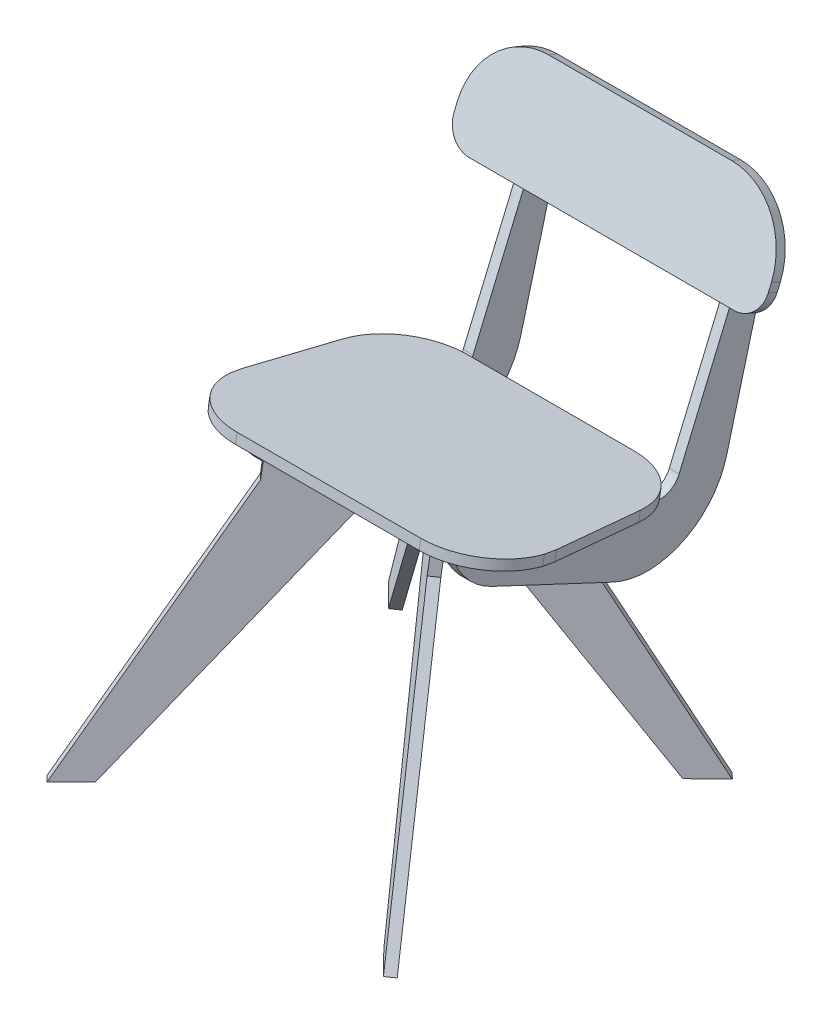
from build123d import *

# Parameters (mm, degrees)
BOSS_EXTRUDE1_DEPTH        = 192.05
BOSS_EXTRUDE1_DEPTH_BACK   = 192.05
BOSS_EXTRUDE1_2_DEPTH      = 192.05
BOSS_EXTRUDE1_2_DEPTH_BACK = 192.05
SKETCH3_OUTSIDE_W          = 508.562
SKETCH3_OUTSIDE_H          = 558.651
CUT_EXTRUDE1_DEPTH         = 12
SKETCH4_OUTSIDE_W          = 508.562
SKETCH4_OUTSIDE_H          = 526.289
CUT_EXTRUDE2_DEPTH         = 12
BOSS_EXTRUDE4_START        = 120
BOSS_EXTRUDE4_DEPTH        = 12
BOSS_EXTRUDE10_DEPTH       = 6


with BuildPart() as part:
    # Sketch2 → Boss-Extrude1 (new, two sides: drawn at the far end of the back side and taken through both)
    with BuildSketch(Plane(origin=(0, 0, 0), x_dir=(0, 0, -1), z_dir=(1, 0, 0)).offset(-BOSS_EXTRUDE1_DEPTH_BACK)):
        Polygon((0, 0), (-270.822132078, 47.753248858), (-272.90591021, 35.935555822), (-2.083778132, -11.817693036), align=None)
    extrude(amount=BOSS_EXTRUDE1_DEPTH + BOSS_EXTRUDE1_DEPTH_BACK)

    # Sketch3 outside → Cut-Extrude1 (cut)
    with BuildSketch(Plane(origin=(0, 0, 0), x_dir=(1, 0, 0), z_dir=(0, 0.9848077530122092, -0.17364817766692398))):
        with Locations((0, -96.4215)):
            Rectangle(SKETCH3_OUTSIDE_W, SKETCH3_OUTSIDE_H)
        with BuildLine():
            Line((0, -275), (112.39737442, -275))
            ThreePointArc((112.39737442, -275), (171.471178999, -248.947063059), (192.068830938, -187.757140317))
            Line((192.068830938, -187.757140317), (181.614285483, -72.757140317))
            ThreePointArc((181.614285483, -72.757140317), (155.889892025, -20.926195422), (101.942828966, 0))
            Line((101.942828966, 0), (-101.942828966, 0))
            ThreePointArc((-101.942828966, 0), (-155.889892025, -20.926195422), (-181.614285483, -72.757140317))
            Line((-181.614285483, -72.757140317), (-192.068830938, -187.757140317))
            ThreePointArc((-192.068830938, -187.757140317), (-171.471178999, -248.947063059), (-112.39737442, -275))
            Line((-112.39737442, -275), (0, -275))
        make_face(mode=Mode.SUBTRACT)
    extrude(amount=-CUT_EXTRUDE1_DEPTH, mode=Mode.SUBTRACT)



with BuildPart() as body_2:
    # Sketch2 → Boss-Extrude1 2 (new, two sides: drawn at the far end of the back side and taken through both)
    with BuildSketch(Plane(origin=(0, 0, 0), x_dir=(0, 0, -1), z_dir=(1, 0, 0)).offset(-BOSS_EXTRUDE1_2_DEPTH_BACK)):
        Polygon((109.404715977, 257.741358967), (62.516980558, 147.280776552), (73.5630388, 142.592003011), (120.450774218, 253.052585425), align=None)
    extrude(amount=BOSS_EXTRUDE1_2_DEPTH + BOSS_EXTRUDE1_2_DEPTH_BACK)

    # Sketch4 outside → Cut-Extrude2 (cut)
    with BuildSketch(Plane(origin=(0, 0, 0), x_dir=(1, 0, 0), z_dir=(0, 0.39073112848927083, 0.9205048534524416))):
        with Locations((0, 83.4025)):
            Rectangle(SKETCH4_OUTSIDE_W, SKETCH4_OUTSIDE_H)
        with BuildLine():
            Line((-112.05, 280), (112.05, 280))
            ThreePointArc((112.05, 280), (168.618542495, 256.568542495), (192.05, 200))
            Line((192.05, 200), (192.05, 190))
            ThreePointArc((192.05, 190), (183.263203436, 168.786796564), (162.05, 160))
            Line((162.05, 160), (-162.05, 160))
            ThreePointArc((-162.05, 160), (-183.263203436, 168.786796564), (-192.05, 190))
            Line((-192.05, 190), (-192.05, 200))
            ThreePointArc((-192.05, 200), (-168.618542495, 256.568542495), (-112.05, 280))
        make_face(mode=Mode.SUBTRACT)
    extrude(amount=-CUT_EXTRUDE2_DEPTH, mode=Mode.SUBTRACT)


with BuildPart() as part_1:
    add(part.part)

    add(body_2.part)  # Boss-Extrude4 merges body 2
    # Sketch6 → Boss-Extrude4 (add)
    with BuildSketch(Plane(origin=(0, 0, 0), x_dir=(0, 0, -1), z_dir=(1, 0, 0)).offset(BOSS_EXTRUDE4_START)):
        with BuildLine():
            Line((-253.20975515, 32.462592269), (-137.494844171, 12.058931393))
            Line((-137.494844171, 12.058931393), (-21.779933192, -8.344729483))
            ThreePointArc((-21.779933192, -8.344729483), (-4.462889813, -36.328759752), (25.301600034, -22.290914988))
            Line((25.301600034, -22.290914988), (91.973135869, 134.777380441))
            ThreePointArc((91.973135869, 134.777380441), (92.106715891, 150.084134879), (81.377661369, 161.00210008))
            Line((81.377661369, 161.00210008), (112.636151649, 234.642488356))
            ThreePointArc((112.636151649, 234.642488356), (132.535530375, 195.215307548), (131.79795497, 151.057139078))
            Line((131.79795497, 151.057139078), (83.48988024, -31.450025326))
            ThreePointArc((83.48988024, -31.450025326), (29.105608653, -96.481302081), (-55.668839629, -96.387117006))
            Line((-55.668839629, -96.387117006), (-203.373392469, -27.062109534))
            ThreePointArc((-203.373392469, -27.062109534), (-234.867841078, -2.805661741), (-253.20975515, 32.462592269))
        make_face()
    boss_extrude4 = extrude(amount=BOSS_EXTRUDE4_DEPTH)

    # Mirror1: Boss-Extrude4 across plane
    add(boss_extrude4.mirror(Plane(origin=(0, 0, 0), x_dir=(0, 0, 1), z_dir=(1, 0, 0))))

    # Sketch27 → Boss-Extrude10 (add, symmetric)
    with BuildSketch(Plane(origin=(68.75, 11.938312215, 67.70553302), x_dir=(0.7071067811865476, -0.12278780396896828, -0.6963642403200198), z_dir=(0.7071067811865476, 0.12278780396896825, 0.6963642403200198))):
        Polygon((52.772817594, -107.537852274), (193.944024949, -293.317225843), (151.463217587, -297.865726007), (-40.700349563, -88.502554793), (-158.448989832, -65.970042163), (-352.630009772, -361.465171741), (-394.307309716, -366.661581013), (-247.22718241, -50.129513852), (-247.22718241, -12.000000012), (52.772817594, -12.000000012), align=None)
    boss_extrude10 = extrude(amount=BOSS_EXTRUDE10_DEPTH, both=True)

    # Mirror3: Boss-Extrude10 across plane
    add(boss_extrude10.mirror(Plane(origin=(0, 0, 0), x_dir=(0, 0, 1), z_dir=(1, 0, 0))))


solid = part_1.part
